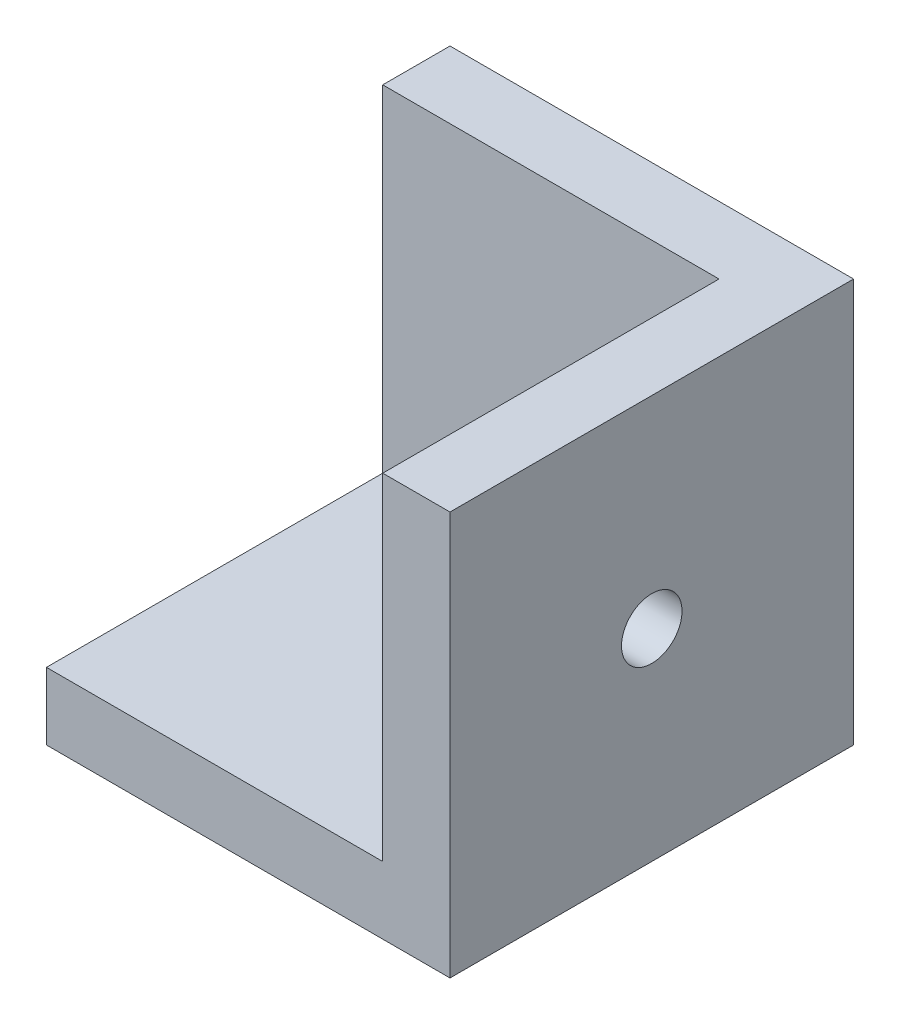
from build123d import *

# Parameters (mm, degrees)
ESBO_O1_W                         = 30
ESBO_O1_H                         = 30
RESSALTO_EXTRUS_O1_DEPTH          = 30
ESBO_O3_W                         = 25
ESBO_O3_H                         = 25
CORTE_EXTRUS_O2_DEPTH             = 25
FURO_COM_FOLGA_DE_M41_D           = 4.5
FURO_COM_FOLGA_DE_M41_ON_FACE_2_D = 4.5
FURO_COM_FOLGA_DE_M32_D           = 3.4


with BuildPart() as part:
    # Esboço1 → Ressalto-extrusão1 (new body)
    with BuildSketch(Plane.XY):
        with Locations((-15, 15)):
            Rectangle(ESBO_O1_W, ESBO_O1_H)
    extrude(amount=RESSALTO_EXTRUS_O1_DEPTH)

    # Esboço3 → Corte-extrusão2 (cut)
    with BuildSketch(Plane(origin=(0, 30, 0), x_dir=(1, 0, 0), z_dir=(0, 1, 0))):
        with Locations((-17.5, -17.5)):
            Rectangle(ESBO_O3_W, ESBO_O3_H)
    extrude(amount=-CORTE_EXTRUS_O2_DEPTH, mode=Mode.SUBTRACT)

    # Furo com folga de M41 (through all)
    with Locations(Plane(origin=(-5, 15, 15), x_dir=(0, 0, -1), z_dir=(-1, 0, 0))):
        with Locations((0, 0)):
            Hole(FURO_COM_FOLGA_DE_M41_D / 2)

    # Furo com folga de M41 on face 2 (through all)
    with Locations(Plane(origin=(-15, 5, 15), x_dir=(0, 0, 1), z_dir=(0, 1, 0))):
        with Locations((0, 0)):
            Hole(FURO_COM_FOLGA_DE_M41_ON_FACE_2_D / 2)

    # Furo com folga de M32 (through all)
    with Locations(Plane(origin=(-15.001293069, 10.996070653, 0), x_dir=(-1, 0, 0), z_dir=(0, 0, -1))):
        with Locations((0, 0)):
            Hole(FURO_COM_FOLGA_DE_M32_D / 2)


solid = part.part
